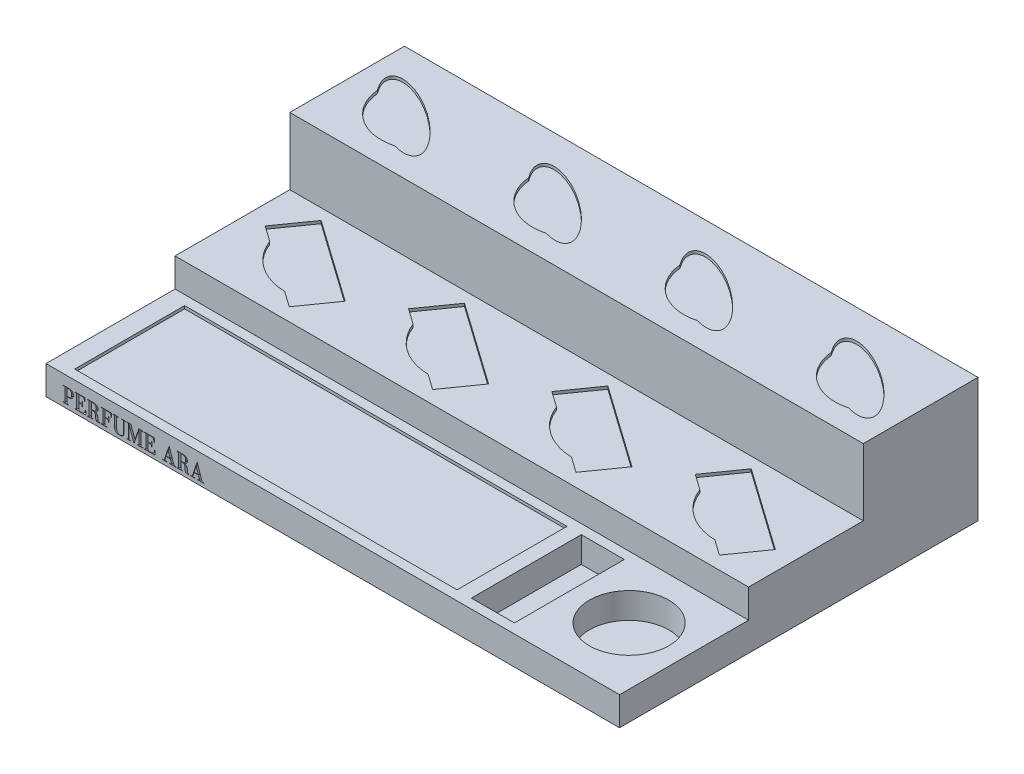
from build123d import *

# Parameters (mm, degrees)
BOSS_EXTRUDE2_DEPTH = 600
CUT_EXTRUDE3_DEPTH  = 3
CUT_EXTRUDE4_DEPTH  = 3
CUT_EXTRUDE6_DEPTH  = 3
SKETCH12_W          = 400
SKETCH12_H          = 115
CUT_EXTRUDE7_DEPTH  = 3
SKETCH13_R          = 41.5
SKETCH13_W          = 45
SKETCH13_H          = 115
CUT_EXTRUDE9_DEPTH  = 27


with BuildPart() as part:
    # Sketch2 → Boss-Extrude2 (new body)
    with BuildSketch(Plane(origin=(0, 0, 0), x_dir=(0, 0, -1), z_dir=(1, 0, 0))):
        Polygon((0, 0), (375, 0), (375, 130), (255, 130), (255, 60), (135, 60), (135, 30), (0, 30), align=None)
    extrude(amount=BOSS_EXTRUDE2_DEPTH)

    # Sketch9 → Cut-Extrude3 (cut)
    with BuildSketch(Plane(origin=(0, 130, 0), x_dir=(1, 0, 0), z_dir=(0, 1, 0))):
        with BuildLine():
            ThreePointArc((25.79283189, 320.948233658), (45.810799047, 286.377522171), (85.191812606, 279.67014765))
            add(Edge.make_bspline(
                [(85.191812606, 279.67014765), (177.980495276, 252.858739242), (72.482840424, 326.172139878), (-33.014814428, 399.485540514), (25.79283189, 320.948233658)],
                knots=[2.350232285, 2.350232285, 2.350232285, 4.722645983, 4.722645983, 7.09505968, 7.09505968, 7.09505968], degree=2, weights=[1, 0.375178634, 1, 0.375178634, 1]))
        make_face()
        with BuildLine():
            ThreePointArc((184.062227688, 320.948233658), (204.080194845, 286.377522171), (243.461208404, 279.67014765))
            add(Edge.make_bspline(
                [(243.461208404, 279.67014765), (336.249891074, 252.858739242), (230.752236222, 326.172139878), (125.25458137, 399.485540514), (184.062227688, 320.948233658)],
                knots=[5.491824939, 5.491824939, 5.491824939, 7.864238636, 7.864238636, 10.236652334, 10.236652334, 10.236652334], degree=2, weights=[1, 0.375178634, 1, 0.375178634, 1]))
        make_face()
        with BuildLine():
            ThreePointArc((342.331623486, 320.948233658), (362.349590643, 286.377522171), (401.730604202, 279.67014765))
            add(Edge.make_bspline(
                [(401.730604202, 279.67014765), (494.519286872, 252.858739242), (389.02163202, 326.172139878), (283.523977168, 399.485540514), (342.331623486, 320.948233658)],
                knots=[5.491824939, 5.491824939, 5.491824939, 7.864238636, 7.864238636, 10.236652334, 10.236652334, 10.236652334], degree=2, weights=[1, 0.375178634, 1, 0.375178634, 1]))
        make_face()
        with BuildLine():
            ThreePointArc((500.601019284, 320.948233658), (520.618986441, 286.377522171), (560, 279.67014765))
            add(Edge.make_bspline(
                [(560, 279.67014765), (652.78868267, 252.858739242), (547.291027818, 326.172139878), (441.793372966, 399.485540514), (500.601019284, 320.948233658)],
                knots=[2.350232285, 2.350232285, 2.350232285, 4.722645983, 4.722645983, 7.09505968, 7.09505968, 7.09505968], degree=2, weights=[1, 0.375178634, 1, 0.375178634, 1]))
        make_face()
    extrude(amount=-CUT_EXTRUDE3_DEPTH, mode=Mode.SUBTRACT)

    # Sketch4 → Cut-Extrude4 (cut)
    with BuildSketch(Plane(origin=(0, 60, 0), x_dir=(1, 0, 0), z_dir=(0, 1, 0))):
        with BuildLine():
            Line((20, 209.248809497), (44.223727413, 243.559318532))
            Line((44.223727413, 243.559318532), (130, 183))
            Line((130, 183), (105.776272587, 148.689490965))
            Line((105.776272587, 148.689490965), (89.437934952, 160.224599257))
            ThreePointArc((89.437934952, 160.224599257), (57.120582148, 170.799981413), (36.338337636, 197.713701205))
            Line((36.338337636, 197.713701205), (20, 209.248809497))
        make_face()
        with BuildLine():
            Line((170, 209.248809497), (194.223727413, 243.559318532))
            Line((194.223727413, 243.559318532), (280, 183))
            Line((280, 183), (255.776272587, 148.689490965))
            Line((255.776272587, 148.689490965), (239.437934952, 160.224599257))
            ThreePointArc((239.437934952, 160.224599257), (207.120582148, 170.799981413), (186.338337636, 197.713701205))
            Line((186.338337636, 197.713701205), (170, 209.248809497))
        make_face()
        with BuildLine():
            Line((320, 209.248809497), (344.223727413, 243.559318532))
            Line((344.223727413, 243.559318532), (430, 183))
            Line((430, 183), (405.776272587, 148.689490965))
            Line((405.776272587, 148.689490965), (389.437934952, 160.224599257))
            ThreePointArc((389.437934952, 160.224599257), (357.120582148, 170.799981413), (336.338337636, 197.713701205))
            Line((336.338337636, 197.713701205), (320, 209.248809497))
        make_face()
        with BuildLine():
            Line((470, 209.248809497), (494.223727413, 243.559318532))
            Line((494.223727413, 243.559318532), (580, 183))
            Line((580, 183), (555.776272587, 148.689490965))
            Line((555.776272587, 148.689490965), (539.437934952, 160.224599257))
            ThreePointArc((539.437934952, 160.224599257), (507.120582148, 170.799981413), (486.338337636, 197.713701205))
            Line((486.338337636, 197.713701205), (470, 209.248809497))
        make_face()
    extrude(amount=-CUT_EXTRUDE4_DEPTH, mode=Mode.SUBTRACT)

    # Sketch11 → Cut-Extrude6 (cut)
    with BuildSketch(Plane.XY):
        with BuildLine():
            Line((23.970966663, 19.403476125), (17.659193065, 19.403476125))
            Line((17.659193065, 19.403476125), (17.659193065, 18.981592563))
            Line((17.659193065, 18.981592563), (19.620292434, 18.981592563))
            Line((19.620292434, 18.981592563), (19.620292434, 4.426609687))
            Line((19.620292434, 4.426609687), (17.659193065, 4.426609687))
            Line((17.659193065, 4.426609687), (17.659193065, 4.004726125))
            Line((17.659193065, 4.004726125), (23.78968857, 4.004726125))
            Line((23.78968857, 4.004726125), (23.78968857, 4.426609687))
            Line((23.78968857, 4.426609687), (21.828589202, 4.426609687))
            Line((21.828589202, 4.426609687), (21.828589202, 10.965804892))
            Line((21.828589202, 10.965804892), (24.198388271, 10.965804892))
            add(Edge.make_bspline(
                [(24.198388271, 10.965804892), (24.362263502, 10.969634799), (24.68330297, 10.97713777), (25.153950282, 11.035122828), (25.603607866, 11.125284598), (26.030479945, 11.258087844), (26.431360897, 11.42627096), (26.806346754, 11.622808925), (27.148579743, 11.855675861), (27.459083097, 12.120820114), (27.741191548, 12.414504641), (27.987366433, 12.738868659), (28.204670843, 13.087716166), (28.384817195, 13.463734895), (28.531642508, 13.865024287), (28.635566174, 14.289361389), (28.700838002, 14.736559784), (28.707270095, 15.04158272), (28.710564801, 15.19782437)],
                knots=[0, 0, 0, 0, 0.000491497, 0.000962866, 0.001420519, 0.001865669, 0.002301498, 0.002723188, 0.003133652, 0.003540486, 0.003946118, 0.004352859, 0.004759881, 0.005177065, 0.005601426, 0.006039492, 0.006485569, 0.006954013, 0.006954013, 0.006954013, 0.006954013], degree=3))
            add(Edge.make_bspline(
                [(28.710564801, 15.19782437), (28.707069749, 15.349648842), (28.700175291, 15.649142948), (28.636590699, 16.087902836), (28.529940265, 16.507144992), (28.3846519, 16.90538784), (28.205382484, 17.283352022), (27.981196857, 17.630066815), (27.72670197, 17.952917853), (27.435388236, 18.246221462), (27.111569514, 18.511730124), (26.752060133, 18.742245309), (26.36273634, 18.945259659), (25.938398894, 19.108110163), (25.486598927, 19.240238323), (25.005947728, 19.336064852), (24.497443763, 19.391788422), (24.149087108, 19.399521881), (23.970966663, 19.403476125)],
                knots=[0, 0, 0, 0, 0.000455273, 0.000898087, 0.001326562, 0.001750923, 0.002168107, 0.002578637, 0.002986831, 0.003399354, 0.003816316, 0.004240511, 0.004678329, 0.005131257, 0.005601658, 0.006089037, 0.006599699, 0.007134012, 0.007134012, 0.007134012, 0.007134012], degree=3))
        make_face()
        with BuildLine():
            Line((21.828589202, 11.387688454), (21.828589202, 18.981592563))
            Line((21.828589202, 18.981592563), (23.970966663, 18.981592563))
            add(Edge.make_bspline(
                [(23.970966663, 18.981592563), (24.074343303, 18.978914527), (24.276253405, 18.973683921), (24.56975571, 18.937311183), (24.846449692, 18.877216323), (25.107220509, 18.796817819), (25.349080817, 18.687194455), (25.57214868, 18.552742157), (25.781603867, 18.399124225), (25.96990012, 18.21541073), (26.142590369, 18.005805745), (26.284695797, 17.758936841), (26.412198173, 17.482966014), (26.513484649, 17.1721739), (26.586961788, 16.827102946), (26.642004577, 16.450565856), (26.680273133, 16.041269419), (26.682428596, 15.757134009), (26.683546126, 15.609820035)],
                knots=[0, 0, 0, 0, 0.000310101, 0.000605674, 0.000885598, 0.001158706, 0.001422754, 0.001679945, 0.001939009, 0.002200078, 0.002467234, 0.002750993, 0.003051866, 0.0033781, 0.003729163, 0.004109058, 0.004519363, 0.004961133, 0.004961133, 0.004961133, 0.004961133], degree=3))
            Line((26.683546126, 15.609820035), (26.683546126, 14.782532739))
            add(Edge.make_bspline(
                [(26.683546126, 14.782532739), (26.681990815, 14.640740851), (26.678972069, 14.365533019), (26.646107097, 13.967999156), (26.590688689, 13.598853324), (26.512084035, 13.260618427), (26.414312325, 12.950786531), (26.291312402, 12.671433888), (26.14798035, 12.420444036), (25.980481649, 12.201195331), (25.79919372, 12.008827111), (25.602837587, 11.844560586), (25.399254548, 11.69937421), (25.178886029, 11.588626624), (24.950527758, 11.499159204), (24.711572531, 11.43089853), (24.458704947, 11.396043371), (24.286371692, 11.3905123), (24.198388271, 11.387688454)],
                knots=[0, 0, 0, 0, 0.000425294, 0.000825466, 0.001195584, 0.001544162, 0.001866241, 0.00216877, 0.002458215, 0.002731124, 0.002994575, 0.003249475, 0.003498162, 0.003742864, 0.003987077, 0.004233372, 0.004486475, 0.004750482, 0.004750482, 0.004750482, 0.004750482], degree=3))
            Line((24.198388271, 11.387688454), (21.828589202, 11.387688454))
        make_face(mode=Mode.SUBTRACT)
        with BuildLine():
            Line((34.366441299, 11.931522732), (36.166038367, 11.931522732))
            add(Edge.make_bspline(
                [(36.166038367, 11.931522732), (36.245205388, 11.929447122), (36.396319488, 11.925485196), (36.609857105, 11.900923765), (36.798597119, 11.855089594), (37.009717814, 11.768728881), (37.238421147, 11.618049189), (37.441950199, 11.361565427), (37.594823045, 11.052579519), (37.699964774, 10.689230195), (37.789162347, 10.279299678), (37.844359048, 9.990344353), (37.873348405, 9.838584751)],
                knots=[0, 0, 0, 0, 0.000237515, 0.00045337, 0.000643624, 0.000818062, 0.001136186, 0.001452273, 0.001788348, 0.00216468, 0.00258367, 0.003047137, 0.003047137, 0.003047137, 0.003047137], degree=3))
            add(Edge.make_bspline(
                [(37.873348405, 9.838584751), (37.883424488, 9.791504368), (37.901183756, 9.708524387), (37.948538722, 9.61214946), (37.992452901, 9.537097779), (38.037869984, 9.526743628), (38.057922464, 9.52217208)],
                knots=[0, 0, 0, 0, 0.0001431, 0.000252215, 0.000327375, 0.000386794, 0.000386794, 0.000386794, 0.000386794], degree=3))
            add(Edge.make_bspline(
                [(38.057922464, 9.52217208), (38.07896925, 9.526547508), (38.122884081, 9.535676987), (38.170111748, 9.601516617), (38.186630503, 9.698057246), (38.190709761, 9.772612501), (38.193057042, 9.815512994)],
                knots=[0, 0, 0, 0, 6.2537e-05, 0.000130485, 0.000225612, 0.000354534, 0.000354534, 0.000354534, 0.000354534], degree=3))
            Line((38.193057042, 9.815512994), (38.193057042, 14.433160414))
            add(Edge.make_bspline(
                [(38.193057042, 14.433160414), (38.19087714, 14.472883015), (38.187072434, 14.542213094), (38.168489329, 14.632137985), (38.123424782, 14.697191531), (38.079028252, 14.703653543), (38.057922464, 14.706725536)],
                knots=[0, 0, 0, 0, 0.000119066, 0.000207813, 0.000275761, 0.000337334, 0.000337334, 0.000337334, 0.000337334], degree=3))
            add(Edge.make_bspline(
                [(38.057922464, 14.706725536), (38.03788223, 14.702147504), (37.992492883, 14.691778668), (37.947744309, 14.61596046), (37.902057898, 14.517764958), (37.883662763, 14.43399029), (37.873348405, 14.3870169)],
                knots=[0, 0, 0, 0, 5.9419e-05, 0.000134578, 0.00024669, 0.000389789, 0.000389789, 0.000389789, 0.000389789], degree=3))
            add(Edge.make_bspline(
                [(37.873348405, 14.3870169), (37.844288626, 14.23528818), (37.788957841, 13.946391655), (37.700882146, 13.537091127), (37.592955174, 13.175058893), (37.444269393, 12.864532385), (37.236015188, 12.611301241), (37.010662748, 12.456633212), (36.798516295, 12.370615326), (36.609882736, 12.324645137), (36.396311957, 12.300126078), (36.245202799, 12.296157836), (36.166038367, 12.294078918)],
                knots=[0, 0, 0, 0, 0.000463467, 0.000882457, 0.001255644, 0.001594664, 0.001908214, 0.002228194, 0.002402632, 0.002592886, 0.002808741, 0.003046256, 0.003046256, 0.003046256, 0.003046256], degree=3))
            Line((36.166038367, 12.294078918), (34.366441299, 12.294078918))
            Line((34.366441299, 12.294078918), (34.366441299, 18.981592563))
            Line((34.366441299, 18.981592563), (37.830500856, 18.981592563))
            add(Edge.make_bspline(
                [(37.830500856, 18.981592563), (37.954997259, 18.977507999), (38.195085671, 18.969631011), (38.540181698, 18.899341745), (38.853975693, 18.78128646), (39.131871555, 18.611491378), (39.383431535, 18.414522838), (39.603269122, 18.186809851), (39.805340715, 17.942696144), (40.028118268, 17.581510752), (40.263108047, 17.101889599), (40.443362189, 16.499654363), (40.565125653, 15.91747208), (40.594971756, 15.53778307), (40.608999625, 15.359326671)],
                knots=[0, 0, 0, 0, 0.000373158, 0.000719627, 0.001051391, 0.001373588, 0.001692735, 0.002007375, 0.002321375, 0.002641406, 0.003278236, 0.003917254, 0.004522277, 0.005058821, 0.005058821, 0.005058821, 0.005058821], degree=3))
            add(Edge.make_bspline(
                [(40.608999625, 15.359326671), (40.609815468, 15.312813011), (40.611268644, 15.22996313), (40.644599832, 15.124449334), (40.706481722, 15.049931721), (40.762353321, 15.043054994), (40.790277718, 15.039618034)],
                knots=[0, 0, 0, 0, 0.000138783, 0.0002472, 0.000328804, 0.000410342, 0.000410342, 0.000410342, 0.000410342], degree=3))
            add(Edge.make_bspline(
                [(40.790277718, 15.039618034), (40.81457486, 15.043721233), (40.864843336, 15.05221036), (40.921853865, 15.118984272), (40.947692164, 15.217856562), (40.950294555, 15.293230754), (40.951780019, 15.336254913)],
                knots=[0, 0, 0, 0, 7.1985e-05, 0.00014893, 0.000245867, 0.00037479, 0.00037479, 0.00037479, 0.00037479], degree=3))
            Line((40.951780019, 15.336254913), (40.951780019, 18.80031447))
            add(Edge.make_bspline(
                [(40.951780019, 18.80031447), (40.949971183, 18.847734151), (40.946573801, 18.936798449), (40.919274141, 19.061180243), (40.8791871, 19.168979904), (40.812671073, 19.255676061), (40.728685377, 19.320494857), (40.630705614, 19.373847296), (40.511147339, 19.397461399), (40.426671652, 19.401382837), (40.381578018, 19.403476125)],
                knots=[0, 0, 0, 0, 0.000142071, 0.00026684, 0.000380682, 0.000484177, 0.0005897, 0.000697312, 0.000815646, 0.000951141, 0.000951141, 0.000951141, 0.000951141], degree=3))
            Line((40.381578018, 19.403476125), (30.197045163, 19.403476125))
            Line((30.197045163, 19.403476125), (30.197045163, 18.981592563))
            Line((30.197045163, 18.981592563), (32.158144531, 18.981592563))
            Line((32.158144531, 18.981592563), (32.158144531, 4.426609687))
            Line((32.158144531, 4.426609687), (30.22011692, 4.426609687))
            Line((30.22011692, 4.426609687), (30.22011692, 4.004726125))
            Line((30.22011692, 4.004726125), (40.928708262, 4.004726125))
            add(Edge.make_bspline(
                [(40.928708262, 4.004726125), (40.980597985, 4.007215093), (41.07918522, 4.011943977), (41.216177724, 4.048198373), (41.335281987, 4.108158434), (41.426886103, 4.200664277), (41.502556121, 4.312972983), (41.554362883, 4.450346848), (41.583129936, 4.612173299), (41.586239303, 4.727513837), (41.587901327, 4.789165872)],
                knots=[0, 0, 0, 0, 0.00015547, 0.000295384, 0.000422182, 0.000550386, 0.000681108, 0.000826168, 0.000987131, 0.00117197, 0.00117197, 0.00117197, 0.00117197], degree=3))
            Line((41.587901327, 4.789165872), (41.587901327, 8.207081915))
            add(Edge.make_bspline(
                [(41.587901327, 8.207081915), (41.587574812, 8.288121461), (41.587010766, 8.428115504), (41.55225768, 8.597724871), (41.503691866, 8.727514373), (41.435514249, 8.746265965), (41.406623234, 8.754212159)],
                knots=[0, 0, 0, 0, 0.000240809, 0.000415992, 0.000532521, 0.000618217, 0.000618217, 0.000618217, 0.000618217], degree=3))
            add(Edge.make_bspline(
                [(41.406623234, 8.754212159), (41.379562429, 8.746858881), (41.315686795, 8.729501849), (41.25301455, 8.619174725), (41.196247123, 8.469987615), (41.170650652, 8.346405092), (41.156129869, 8.276297187)],
                knots=[0, 0, 0, 0, 8.1404e-05, 0.000192151, 0.000354959, 0.00056841, 0.00056841, 0.00056841, 0.00056841], degree=3))
            add(Edge.make_bspline(
                [(41.156129869, 8.276297187), (41.095423397, 8.000117296), (40.979506581, 7.472761773), (40.812413243, 6.834595737), (40.659769419, 6.369171943), (40.537218057, 6.04914472), (40.386012238, 5.757730809), (40.227840213, 5.48496103), (40.044015815, 5.241900439), (39.840633565, 5.025639587), (39.609817026, 4.843284547), (39.356584428, 4.688639654), (39.07269221, 4.568308758), (38.755634117, 4.48935702), (38.407047443, 4.433585303), (38.162543976, 4.429002881), (38.034850706, 4.426609687)],
                knots=[0, 0, 0, 0, 0.000848351, 0.001619896, 0.001977398, 0.002317697, 0.002646403, 0.002961249, 0.003262501, 0.00355857, 0.0038494, 0.004142204, 0.004446452, 0.004770229, 0.0051203, 0.005502987, 0.005502987, 0.005502987, 0.005502987], degree=3))
            Line((38.034850706, 4.426609687), (34.366441299, 4.426609687))
            Line((34.366441299, 4.426609687), (34.366441299, 11.931522732))
        make_face()
        with BuildLine():
            add(Edge.make_bspline(
                [(54.554228917, 5.000107653), (54.532897788, 5.091005236), (54.48346668, 5.301644262), (54.442961059, 5.6594668), (54.421607853, 6.079904909), (54.399422433, 6.540222899), (54.39420347, 7.023919809), (54.379602152, 7.51715092), (54.364988929, 8.005318829), (54.32381311, 8.324844531), (54.303735552, 8.480647037)],
                knots=[0, 0, 0, 0, 0.000279924, 0.000648675, 0.001077961, 0.001543113, 0.002031016, 0.002528881, 0.003023814, 0.003494803, 0.003494803, 0.003494803, 0.003494803], degree=3))
            add(Edge.make_bspline(
                [(54.303735552, 8.480647037), (54.279948569, 8.627303558), (54.234132588, 8.909777896), (54.126810312, 9.30791232), (54.003535682, 9.667577579), (53.853645651, 9.98702847), (53.683471204, 10.272305434), (53.49914362, 10.532152909), (53.294739508, 10.7618477), (53.074670986, 10.967197776), (52.834634921, 11.142586154), (52.584012333, 11.308943431), (52.30997175, 11.444374565), (51.919282847, 11.60343641), (51.398486062, 11.780019133), (50.968831117, 11.899570305), (50.747388966, 11.96118642)],
                knots=[0, 0, 0, 0, 0.000445443, 0.000857966, 0.001235322, 0.001584772, 0.001914319, 0.0022308, 0.002539004, 0.002835219, 0.003131856, 0.0034299, 0.003736495, 0.004046824, 0.00469515, 0.005384668, 0.005384668, 0.005384668, 0.005384668], degree=3))
            add(Edge.make_bspline(
                [(50.747388966, 11.96118642), (50.891667453, 11.989186161), (51.173316939, 12.043845124), (51.580359965, 12.151886303), (51.95980126, 12.286016107), (52.316289813, 12.431339119), (52.64516761, 12.601497019), (52.949458531, 12.789687205), (53.23036772, 12.995844845), (53.48251291, 13.225219071), (53.705858078, 13.471897668), (53.902753737, 13.733629443), (54.067378677, 14.011494273), (54.20421183, 14.30372058), (54.309524141, 14.612119484), (54.386287946, 14.936445562), (54.42788828, 15.27694893), (54.435171537, 15.50864144), (54.438870131, 15.626299862)],
                knots=[0, 0, 0, 0, 0.000440847, 0.000860588, 0.001261898, 0.001647526, 0.002014579, 0.00237129, 0.002720008, 0.003058339, 0.003392014, 0.003716997, 0.004039193, 0.004359173, 0.004683336, 0.005015117, 0.005357295, 0.005710348, 0.005710348, 0.005710348, 0.005710348], degree=3))
            add(Edge.make_bspline(
                [(54.438870131, 15.626299862), (54.434574013, 15.77159156), (54.426158379, 16.056202449), (54.356039011, 16.471838936), (54.23668367, 16.863655324), (54.070986745, 17.23044755), (53.864922776, 17.57044017), (53.627518535, 17.885279924), (53.35549583, 18.170703453), (53.049572882, 18.424419233), (52.7159548, 18.653061795), (52.350489299, 18.851874993), (51.954699139, 19.018825358), (51.531704573, 19.155671081), (51.089474407, 19.268185582), (50.629918543, 19.346733875), (50.157284848, 19.39340431), (49.837807491, 19.400092773), (49.676200235, 19.403476125)],
                knots=[0, 0, 0, 0, 0.000435679, 0.000853448, 0.001260069, 0.001661325, 0.002057568, 0.002450452, 0.002842104, 0.003237523, 0.003640684, 0.004053667, 0.004483421, 0.004927435, 0.005386285, 0.005851203, 0.00632478, 0.006809567, 0.006809567, 0.006809567, 0.006809567], degree=3))
            Line((49.676200235, 19.403476125), (43.252363816, 19.403476125))
            Line((43.252363816, 19.403476125), (43.252363816, 18.981592563))
            Line((43.252363816, 18.981592563), (45.213463185, 18.981592563))
            Line((45.213463185, 18.981592563), (45.213463185, 4.439793548))
            Line((45.213463185, 4.439793548), (43.252363816, 4.439793548))
            Line((43.252363816, 4.439793548), (43.252363816, 4.073941397))
            Line((43.252363816, 4.073941397), (49.382859321, 4.073941397))
            Line((49.382859321, 4.073941397), (49.382859321, 4.439793548))
            Line((49.382859321, 4.439793548), (47.421759953, 4.439793548))
            Line((47.421759953, 4.439793548), (47.421759953, 11.868899391))
            Line((47.421759953, 11.868899391), (49.31364405, 11.868899391))
            add(Edge.make_bspline(
                [(49.31364405, 11.868899391), (49.439411632, 11.863119198), (49.700954704, 11.851098853), (50.025585388, 11.767880923), (50.290682835, 11.671260697), (50.488340608, 11.566592936), (50.673824179, 11.426541262), (50.856208786, 11.265971436), (51.029964177, 11.07296049), (51.186276928, 10.842652506), (51.336082257, 10.581320177), (51.46980935, 10.28275346), (51.593637892, 9.946535827), (51.697349099, 9.567228325), (51.783488098, 9.143318407), (51.82166841, 8.844614617), (51.841649454, 8.688292852)],
                knots=[0, 0, 0, 0, 0.000376909, 0.000783811, 0.000998681, 0.001222807, 0.001451562, 0.001694348, 0.001951095, 0.002228132, 0.002527793, 0.002853761, 0.003208288, 0.003601724, 0.004032223, 0.00450487, 0.00450487, 0.00450487, 0.00450487], degree=3))
            add(Edge.make_bspline(
                [(51.841649454, 8.688292852), (51.86317103, 8.489626133), (51.906490786, 8.089739361), (51.919614395, 7.486262003), (51.939177131, 6.889144402), (51.983015724, 6.312155885), (52.05842794, 5.767582699), (52.160735419, 5.341172069), (52.274285385, 5.027737505), (52.381962426, 4.813599856), (52.508499718, 4.615263346), (52.611369853, 4.497933632), (52.66234482, 4.439793548)],
                knots=[0, 0, 0, 0, 0.000599195, 0.001206092, 0.001809694, 0.002391617, 0.002941174, 0.003457579, 0.003703697, 0.003939537, 0.004175401, 0.004407081, 0.004407081, 0.004407081, 0.004407081], degree=3))
            add(Edge.make_bspline(
                [(52.66234482, 4.439793548), (52.712348924, 4.388409582), (52.810325867, 4.287728968), (52.983690018, 4.171513386), (53.16113977, 4.066964465), (53.425016656, 3.979385657), (53.776144143, 3.910486359), (54.063846245, 3.898706715), (54.211448523, 3.892663304)],
                knots=[0, 0, 0, 0, 0.000214466, 0.00042022, 0.000623824, 0.000830237, 0.001250391, 0.001693046, 0.001693046, 0.001693046, 0.001693046], degree=3))
            add(Edge.make_bspline(
                [(54.211448523, 3.892663304), (54.340229108, 3.896417173), (54.599134404, 3.903964093), (54.982500087, 3.966795236), (55.349978321, 4.055576654), (55.694488546, 4.155633493), (55.999170336, 4.272250428), (56.258961015, 4.394949642), (56.471863926, 4.507972593), (56.58026662, 4.602883862), (56.627391107, 4.644143398)],
                knots=[0, 0, 0, 0, 0.000386135, 0.0007763, 0.001162434, 0.001520119, 0.001851883, 0.002139408, 0.002383064, 0.002570442, 0.002570442, 0.002570442, 0.002570442], degree=3))
            add(Edge.make_bspline(
                [(56.627391107, 4.644143398), (56.646540222, 4.665982508), (56.68098633, 4.705267474), (56.689520512, 4.756518275), (56.693310413, 4.779277976)],
                knots=[0, 0, 0, 0, 8.5059e-05, 0.000153007, 0.000153007, 0.000153007, 0.000153007], degree=3))
            add(Edge.make_bspline(
                [(56.693310413, 4.779277976), (56.690899238, 4.799880954), (56.686213774, 4.839917245), (56.646613015, 4.845690806), (56.627391107, 4.848493248)],
                knots=[0, 0, 0, 0, 5.525e-05, 0.000107364, 0.000107364, 0.000107364, 0.000107364], degree=3))
            add(Edge.make_bspline(
                [(56.627391107, 4.848493248), (56.608447448, 4.844853743), (56.559423838, 4.8354352), (56.515754955, 4.810845545), (56.488960563, 4.795757803)],
                knots=[0, 0, 0, 0, 5.7562e-05, 0.000148961, 0.000148961, 0.000148961, 0.000148961], degree=3))
            add(Edge.make_bspline(
                [(56.488960563, 4.795757803), (56.412796009, 4.738910603), (56.262758052, 4.626926257), (56.007850004, 4.512588697), (55.740482243, 4.439317224), (55.556684252, 4.430872179), (55.463915347, 4.426609687)],
                knots=[0, 0, 0, 0, 0.000284333, 0.000560113, 0.000832723, 0.001110544, 0.001110544, 0.001110544, 0.001110544], degree=3))
            add(Edge.make_bspline(
                [(55.463915347, 4.426609687), (55.356202299, 4.432382524), (55.154023614, 4.443218208), (54.8809577, 4.554624371), (54.669173643, 4.744496083), (54.593510106, 4.912755004), (54.554228917, 5.000107653)],
                knots=[0, 0, 0, 0, 0.000321758, 0.000603943, 0.000867559, 0.001152178, 0.001152178, 0.001152178, 0.001152178], degree=3))
        make_face()
        with BuildLine():
            Line((47.421759953, 12.21497575), (47.421759953, 18.981592563))
            Line((47.421759953, 18.981592563), (49.676200235, 18.981592563))
            add(Edge.make_bspline(
                [(49.676200235, 18.981592563), (49.780635268, 18.978526951), (49.984529487, 18.972541788), (50.280658673, 18.94166836), (50.556602378, 18.881797964), (50.81086843, 18.798403353), (51.047931723, 18.698759048), (51.260428588, 18.566347735), (51.456235111, 18.416314574), (51.628669772, 18.238636648), (51.782384142, 18.039057157), (51.912586254, 17.814206199), (52.025462198, 17.568255823), (52.11850226, 17.300337209), (52.185387989, 17.007041183), (52.239190859, 16.6925862), (52.268006965, 16.353046771), (52.271573482, 16.119644568), (52.273420912, 15.998743944)],
                knots=[0, 0, 0, 0, 0.000313394, 0.000611856, 0.000891781, 0.001158612, 0.001413958, 0.00166098, 0.001907561, 0.002152285, 0.002401474, 0.002661501, 0.002929915, 0.003212389, 0.003510578, 0.003831355, 0.00416885, 0.004531541, 0.004531541, 0.004531541, 0.004531541], degree=3))
            Line((52.273420912, 15.998743944), (52.273420912, 15.178048578))
            add(Edge.make_bspline(
                [(52.273420912, 15.178048578), (52.271532506, 15.05824918), (52.267870774, 14.825950972), (52.239429444, 14.488565166), (52.185476534, 14.176294919), (52.11799756, 13.88536146), (52.02539259, 13.618473427), (51.913372049, 13.373127252), (51.782399225, 13.150733017), (51.62768557, 12.954272463), (51.456169214, 12.777189916), (51.261526777, 12.626068488), (51.045976053, 12.499487004), (50.812549668, 12.392788482), (50.555734168, 12.316219748), (50.280817023, 12.254455782), (49.984486473, 12.22414718), (49.780620699, 12.21808223), (49.676200235, 12.21497575)],
                knots=[0, 0, 0, 0, 0.000359396, 0.000696891, 0.001014417, 0.001309402, 0.001591876, 0.00186029, 0.00211748, 0.002364062, 0.002608786, 0.002855367, 0.00310069, 0.003357373, 0.003623205, 0.003903129, 0.004201591, 0.004514986, 0.004514986, 0.004514986, 0.004514986], degree=3))
            Line((49.676200235, 12.21497575), (47.421759953, 12.21497575))
        make_face(mode=Mode.SUBTRACT)
        with BuildLine():
            Line((57.711763699, 18.981592563), (59.669567102, 18.981592563))
            Line((59.669567102, 18.981592563), (59.669567102, 4.426609687))
            Line((59.669567102, 4.426609687), (57.757907213, 4.426609687))
            Line((57.757907213, 4.426609687), (57.757907213, 4.004726125))
            Line((57.757907213, 4.004726125), (63.838963238, 4.004726125))
            Line((63.838963238, 4.004726125), (63.838963238, 4.426609687))
            Line((63.838963238, 4.426609687), (61.881159835, 4.426609687))
            Line((61.881159835, 4.426609687), (61.881159835, 11.931522732))
            Line((61.881159835, 11.931522732), (63.680756903, 11.931522732))
            add(Edge.make_bspline(
                [(63.680756903, 11.931522732), (63.759948352, 11.92956696), (63.910018509, 11.925860713), (64.123229395, 11.899917366), (64.311633219, 11.856514792), (64.522304469, 11.766650793), (64.753078688, 11.619600123), (64.956316505, 11.361265909), (65.11037478, 11.053234488), (65.210378978, 10.688546308), (65.300235515, 10.279056475), (65.357809233, 9.990326166), (65.388066941, 9.838584751)],
                knots=[0, 0, 0, 0, 0.000237515, 0.000450099, 0.000643553, 0.000814943, 0.001135805, 0.001451891, 0.001787966, 0.00216333, 0.00258232, 0.003046431, 0.003046431, 0.003046431, 0.003046431], degree=3))
            add(Edge.make_bspline(
                [(65.388066941, 9.838584751), (65.398758814, 9.791844987), (65.417502374, 9.709907084), (65.458816825, 9.609934565), (65.506532627, 9.538885509), (65.550712867, 9.527129817), (65.569345034, 9.52217208)],
                knots=[0, 0, 0, 0, 0.0001431, 0.000250863, 0.00032809, 0.000384411, 0.000384411, 0.000384411, 0.000384411], degree=3))
            add(Edge.make_bspline(
                [(65.569345034, 9.52217208), (65.590188044, 9.526733291), (65.634385973, 9.536405411), (65.685565378, 9.600060693), (65.701008423, 9.698357242), (65.705303887, 9.772722074), (65.707775578, 9.815512994)],
                knots=[0, 0, 0, 0, 6.2537e-05, 0.00013261, 0.000227737, 0.000356659, 0.000356659, 0.000356659, 0.000356659], degree=3))
            Line((65.707775578, 9.815512994), (65.707775578, 14.433160414))
            add(Edge.make_bspline(
                [(65.707775578, 14.433160414), (65.705483891, 14.472784874), (65.701484081, 14.541943662), (65.683862925, 14.633531818), (65.634942661, 14.696499944), (65.590249064, 14.703466942), (65.569345034, 14.706725536)],
                knots=[0, 0, 0, 0, 0.000119066, 0.000207813, 0.000277886, 0.00033946, 0.00033946, 0.00033946, 0.00033946], degree=3))
            add(Edge.make_bspline(
                [(65.569345034, 14.706725536), (65.550722894, 14.701762974), (65.506566432, 14.68999584), (65.45798514, 14.618182065), (65.418360254, 14.516420643), (65.398986385, 14.433661416), (65.388066941, 14.3870169)],
                knots=[0, 0, 0, 0, 5.6321e-05, 0.000133548, 0.000244344, 0.000387443, 0.000387443, 0.000387443, 0.000387443], degree=3))
            add(Edge.make_bspline(
                [(65.388066941, 14.3870169), (65.357739677, 14.235305749), (65.300033611, 13.946633028), (65.211288014, 13.537783833), (65.108524635, 13.174392381), (64.958630886, 12.864835141), (64.750672428, 12.609767343), (64.523231156, 12.458725027), (64.311552521, 12.369191127), (64.123254413, 12.325651959), (63.910011117, 12.299750487), (63.759945799, 12.296037989), (63.680756903, 12.294078918)],
                knots=[0, 0, 0, 0, 0.000464111, 0.000883101, 0.001255312, 0.001594332, 0.001907882, 0.002230584, 0.002401974, 0.002595428, 0.002808011, 0.003045526, 0.003045526, 0.003045526, 0.003045526], degree=3))
            Line((63.680756903, 12.294078918), (61.881159835, 12.294078918))
            Line((61.881159835, 12.294078918), (61.881159835, 18.981592563))
            Line((61.881159835, 18.981592563), (65.341923427, 18.981592563))
            add(Edge.make_bspline(
                [(65.341923427, 18.981592563), (65.466418549, 18.977506724), (65.70650449, 18.969627277), (66.051617791, 18.899355203), (66.365350419, 18.781238847), (66.643466602, 18.611663023), (66.894829338, 18.413411711), (67.118078996, 18.187989452), (67.319903006, 17.942540918), (67.542927184, 17.581600543), (67.777795746, 17.101858963), (67.958088505, 16.499662092), (68.079842538, 15.91747044), (68.109689764, 15.537782545), (68.123718161, 15.359326671)],
                knots=[0, 0, 0, 0, 0.000373158, 0.000719627, 0.001051391, 0.001373588, 0.001692735, 0.002009697, 0.002323697, 0.002643728, 0.003280558, 0.003919576, 0.004524599, 0.005061143, 0.005061143, 0.005061143, 0.005061143], degree=3))
            add(Edge.make_bspline(
                [(68.123718161, 15.359326671), (68.124534004, 15.312813011), (68.12598718, 15.22996313), (68.159318368, 15.124449334), (68.221200258, 15.049931721), (68.277071857, 15.043054994), (68.304996254, 15.039618034)],
                knots=[0, 0, 0, 0, 0.000138783, 0.0002472, 0.000328804, 0.000410342, 0.000410342, 0.000410342, 0.000410342], degree=3))
            add(Edge.make_bspline(
                [(68.304996254, 15.039618034), (68.32950005, 15.043516762), (68.379440251, 15.051462601), (68.432742564, 15.120393385), (68.459392344, 15.217594008), (68.461818005, 15.293135346), (68.46320259, 15.336254913)],
                knots=[0, 0, 0, 0, 7.1985e-05, 0.00014671, 0.000243647, 0.000372569, 0.000372569, 0.000372569, 0.000372569], degree=3))
            Line((68.46320259, 15.336254913), (68.46320259, 18.80031447))
            add(Edge.make_bspline(
                [(68.46320259, 18.80031447), (68.461393753, 18.847734151), (68.457996371, 18.936798449), (68.430696711, 19.061180243), (68.390609671, 19.168979904), (68.324093644, 19.255676061), (68.240107947, 19.320494857), (68.142128185, 19.373847296), (68.02256991, 19.397461399), (67.938094223, 19.401382837), (67.893000589, 19.403476125)],
                knots=[0, 0, 0, 0, 0.000142071, 0.00026684, 0.000380682, 0.000484177, 0.0005897, 0.000697312, 0.000815646, 0.000951141, 0.000951141, 0.000951141, 0.000951141], degree=3))
            Line((67.893000589, 19.403476125), (57.711763699, 19.403476125))
            Line((57.711763699, 19.403476125), (57.711763699, 18.981592563))
        make_face()
        with BuildLine():
            Line((75.941747913, 19.403476125), (69.814548373, 19.403476125))
            Line((69.814548373, 19.403476125), (69.814548373, 18.981592563))
            Line((69.814548373, 18.981592563), (71.772351777, 18.981592563))
            Line((71.772351777, 18.981592563), (71.772351777, 7.841229764))
            add(Edge.make_bspline(
                [(71.772351777, 7.841229764), (71.77755125, 7.648575655), (71.787594636, 7.276441876), (71.878107456, 6.744024127), (72.021309002, 6.258076457), (72.228409131, 5.824056585), (72.481858155, 5.436092699), (72.769802237, 5.089220086), (73.089242062, 4.77844271), (73.442574641, 4.50807719), (73.826018827, 4.279143326), (74.229594022, 4.083576141), (74.654251742, 3.924198968), (75.097428515, 3.80455252), (75.549689405, 3.717611828), (76.003094694, 3.655499971), (76.452938314, 3.61357371), (76.752464978, 3.60845201), (76.900873823, 3.605914321)],
                knots=[0, 0, 0, 0, 0.000577556, 0.001115617, 0.001615051, 0.002092738, 0.002552582, 0.003002019, 0.003442558, 0.003886878, 0.004333429, 0.00478009, 0.005230662, 0.005692027, 0.006155494, 0.006611363, 0.007064639, 0.00750979, 0.00750979, 0.00750979, 0.00750979], degree=3))
            add(Edge.make_bspline(
                [(76.900873823, 3.605914321), (77.075677388, 3.608953601), (77.417224019, 3.614892015), (77.914160996, 3.664620644), (78.382582614, 3.746761565), (78.820781414, 3.8609958), (79.230293526, 4.008788967), (79.606488649, 4.195172735), (79.955740883, 4.409411259), (80.273548568, 4.657559609), (80.560186619, 4.938837799), (80.806873267, 5.256599436), (81.018095543, 5.606484914), (81.183982715, 5.991197904), (81.317137294, 6.407238323), (81.411438139, 6.855515486), (81.46777079, 7.337709903), (81.475154242, 7.669682216), (81.47896966, 7.841229764)],
                knots=[0, 0, 0, 0, 0.000524318, 0.001024458, 0.001496437, 0.001949725, 0.002381409, 0.002800035, 0.003207057, 0.003608584, 0.004007123, 0.004408649, 0.00481224, 0.005229893, 0.005662468, 0.006120797, 0.006601986, 0.007116536, 0.007116536, 0.007116536, 0.007116536], degree=3))
            Line((81.47896966, 7.841229764), (81.47896966, 18.981592563))
            Line((81.47896966, 18.981592563), (83.436773063, 18.981592563))
            Line((83.436773063, 18.981592563), (83.436773063, 19.403476125))
            Line((83.436773063, 19.403476125), (79.155314105, 19.403476125))
            Line((79.155314105, 19.403476125), (79.155314105, 18.981592563))
            Line((79.155314105, 18.981592563), (81.113117509, 18.981592563))
            Line((81.113117509, 18.981592563), (81.113117509, 7.841229764))
            add(Edge.make_bspline(
                [(81.113117509, 7.841229764), (81.110364555, 7.693841101), (81.104983662, 7.405756883), (81.050930764, 6.985321043), (80.963086985, 6.58750482), (80.836688036, 6.215206401), (80.682919095, 5.86763028), (80.497424138, 5.549846062), (80.284616939, 5.261035207), (80.048497266, 4.999786679), (79.784322365, 4.771498169), (79.502077178, 4.569103576), (79.194403316, 4.400866521), (78.870558195, 4.259150298), (78.527789767, 4.150540982), (78.172794287, 4.071395863), (77.803019721, 4.02447326), (77.552510119, 4.017940818), (77.42493231, 4.014614021)],
                knots=[0, 0, 0, 0, 0.000441967, 0.000863863, 0.001269267, 0.001662206, 0.002041371, 0.002407683, 0.002763663, 0.003115961, 0.003461676, 0.003809194, 0.004155897, 0.004511648, 0.004868131, 0.005232778, 0.005601529, 0.005984216, 0.005984216, 0.005984216, 0.005984216], degree=3))
            add(Edge.make_bspline(
                [(77.42493231, 4.014614021), (77.295137004, 4.017802621), (77.04238914, 4.024011719), (76.674083738, 4.071593438), (76.325683881, 4.145745554), (75.999002086, 4.255201695), (75.691972454, 4.393871218), (75.40786343, 4.567084435), (75.142621422, 4.768028556), (74.901526844, 5.001044562), (74.681257284, 5.259892819), (74.500182077, 5.554524317), (74.333405678, 5.867604978), (74.209505929, 6.212938058), (74.103068764, 6.580874636), (74.039594999, 6.978311257), (73.988654027, 7.400464534), (73.985542918, 7.691634254), (73.98394451, 7.841229764)],
                knots=[0, 0, 0, 0, 0.000389273, 0.000758024, 0.001112305, 0.001456256, 0.001789589, 0.002120829, 0.002452414, 0.002785763, 0.003125055, 0.003468849, 0.003821162, 0.004187252, 0.004567104, 0.00496863, 0.00539303, 0.005841475, 0.005841475, 0.005841475, 0.005841475], degree=3))
            Line((73.98394451, 7.841229764), (73.98394451, 18.981592563))
            Line((73.98394451, 18.981592563), (75.941747913, 18.981592563))
            Line((75.941747913, 18.981592563), (75.941747913, 19.403476125))
        make_face()
        Polygon((84.643096372, 4.426609687), (84.643096372, 4.004726125), (88.654286173, 4.004726125), (88.654286173, 4.426609687), (86.831617348, 4.426609687), (86.831617348, 18.619036378), (91.910699914, 4.004726125), (92.207336794, 4.004726125), (97.28641936, 18.708027441), (97.28641936, 4.426609687), (95.463750535, 4.426609687), (95.463750535, 4.004726125), (101.320680918, 4.004726125), (101.320680918, 4.426609687), (99.498012093, 4.426609687), (99.498012093, 18.981592563), (101.320680918, 18.981592563), (101.320680918, 19.403476125), (97.105141267, 19.403476125), (93.051103917, 7.692911324), (88.858636023, 19.403476125), (84.643096372, 19.403476125), (84.643096372, 18.981592563), (86.465765197, 18.981592563), (86.465765197, 4.426609687), align=None)
        with BuildLine():
            Line((106.930413902, 11.931522732), (108.73001097, 11.931522732))
            add(Edge.make_bspline(
                [(108.73001097, 11.931522732), (108.809177991, 11.929447122), (108.960292091, 11.925485196), (109.173829708, 11.900923765), (109.362569722, 11.855089594), (109.573690416, 11.768728881), (109.80239375, 11.618049189), (110.005922801, 11.361565427), (110.158795648, 11.052579519), (110.263937377, 10.689230195), (110.35313495, 10.279299678), (110.40833165, 9.990344353), (110.437321008, 9.838584751)],
                knots=[0, 0, 0, 0, 0.000237515, 0.00045337, 0.000643624, 0.000818062, 0.001136186, 0.001452273, 0.001788348, 0.00216468, 0.00258367, 0.003047137, 0.003047137, 0.003047137, 0.003047137], degree=3))
            add(Edge.make_bspline(
                [(110.437321008, 9.838584751), (110.447397091, 9.791504368), (110.465156359, 9.708524387), (110.512511325, 9.61214946), (110.556425504, 9.537097779), (110.601842587, 9.526743628), (110.621895066, 9.52217208)],
                knots=[0, 0, 0, 0, 0.0001431, 0.000252215, 0.000327375, 0.000386794, 0.000386794, 0.000386794, 0.000386794], degree=3))
            add(Edge.make_bspline(
                [(110.621895066, 9.52217208), (110.642941853, 9.526547508), (110.686856684, 9.535676987), (110.734084351, 9.601516617), (110.750603106, 9.698057246), (110.754682363, 9.772612501), (110.757029645, 9.815512994)],
                knots=[0, 0, 0, 0, 6.2537e-05, 0.000130485, 0.000225612, 0.000354534, 0.000354534, 0.000354534, 0.000354534], degree=3))
            Line((110.757029645, 9.815512994), (110.757029645, 14.433160414))
            add(Edge.make_bspline(
                [(110.757029645, 14.433160414), (110.754849742, 14.472883015), (110.751045037, 14.542213094), (110.732461932, 14.632137985), (110.687397385, 14.697191531), (110.643000854, 14.703653543), (110.621895066, 14.706725536)],
                knots=[0, 0, 0, 0, 0.000119066, 0.000207813, 0.000275761, 0.000337334, 0.000337334, 0.000337334, 0.000337334], degree=3))
            add(Edge.make_bspline(
                [(110.621895066, 14.706725536), (110.601854833, 14.702147504), (110.556465486, 14.691778668), (110.511716912, 14.61596046), (110.466030501, 14.517764958), (110.447635365, 14.43399029), (110.437321008, 14.3870169)],
                knots=[0, 0, 0, 0, 5.9419e-05, 0.000134578, 0.00024669, 0.000389789, 0.000389789, 0.000389789, 0.000389789], degree=3))
            add(Edge.make_bspline(
                [(110.437321008, 14.3870169), (110.408261229, 14.23528818), (110.352930444, 13.946391655), (110.264854749, 13.537091127), (110.156927777, 13.175058893), (110.008241995, 12.864532385), (109.79998779, 12.611301241), (109.57463535, 12.456633212), (109.362488898, 12.370615326), (109.173855338, 12.324645137), (108.960284559, 12.300126078), (108.809175402, 12.296157836), (108.73001097, 12.294078918)],
                knots=[0, 0, 0, 0, 0.000463467, 0.000882457, 0.001255644, 0.001594664, 0.001908214, 0.002228194, 0.002402632, 0.002592886, 0.002808741, 0.003046256, 0.003046256, 0.003046256, 0.003046256], degree=3))
            Line((108.73001097, 12.294078918), (106.930413902, 12.294078918))
            Line((106.930413902, 12.294078918), (106.930413902, 18.981592563))
            Line((106.930413902, 18.981592563), (110.394473459, 18.981592563))
            add(Edge.make_bspline(
                [(110.394473459, 18.981592563), (110.518969862, 18.977507999), (110.759058274, 18.969631011), (111.1041543, 18.899341745), (111.417948295, 18.78128646), (111.695844157, 18.611491378), (111.947404138, 18.414522838), (112.167241725, 18.186809851), (112.369313318, 17.942696144), (112.592090871, 17.581510752), (112.82708065, 17.101889599), (113.007334792, 16.499654363), (113.129098256, 15.91747208), (113.158944358, 15.53778307), (113.172972228, 15.359326671)],
                knots=[0, 0, 0, 0, 0.000373158, 0.000719627, 0.001051391, 0.001373588, 0.001692735, 0.002007375, 0.002321375, 0.002641406, 0.003278236, 0.003917254, 0.004522277, 0.005058821, 0.005058821, 0.005058821, 0.005058821], degree=3))
            add(Edge.make_bspline(
                [(113.172972228, 15.359326671), (113.173788071, 15.312813011), (113.175241246, 15.22996313), (113.208572434, 15.124449334), (113.270454325, 15.049931721), (113.326325924, 15.043054994), (113.354250321, 15.039618034)],
                knots=[0, 0, 0, 0, 0.000138783, 0.0002472, 0.000328804, 0.000410342, 0.000410342, 0.000410342, 0.000410342], degree=3))
            add(Edge.make_bspline(
                [(113.354250321, 15.039618034), (113.378547463, 15.043721233), (113.428815939, 15.05221036), (113.485826468, 15.118984272), (113.511664767, 15.217856562), (113.514267158, 15.293230754), (113.515752622, 15.336254913)],
                knots=[0, 0, 0, 0, 7.1985e-05, 0.00014893, 0.000245867, 0.00037479, 0.00037479, 0.00037479, 0.00037479], degree=3))
            Line((113.515752622, 15.336254913), (113.515752622, 18.80031447))
            add(Edge.make_bspline(
                [(113.515752622, 18.80031447), (113.513943785, 18.847734151), (113.510546403, 18.936798449), (113.483246743, 19.061180243), (113.443159703, 19.168979904), (113.376643676, 19.255676061), (113.29265798, 19.320494857), (113.194678217, 19.373847296), (113.075119942, 19.397461399), (112.990644255, 19.401382837), (112.945550621, 19.403476125)],
                knots=[0, 0, 0, 0, 0.000142071, 0.00026684, 0.000380682, 0.000484177, 0.0005897, 0.000697312, 0.000815646, 0.000951141, 0.000951141, 0.000951141, 0.000951141], degree=3))
            Line((112.945550621, 19.403476125), (102.761017765, 19.403476125))
            Line((102.761017765, 19.403476125), (102.761017765, 18.981592563))
            Line((102.761017765, 18.981592563), (104.722117134, 18.981592563))
            Line((104.722117134, 18.981592563), (104.722117134, 4.426609687))
            Line((104.722117134, 4.426609687), (102.784089523, 4.426609687))
            Line((102.784089523, 4.426609687), (102.784089523, 4.004726125))
            Line((102.784089523, 4.004726125), (113.492680865, 4.004726125))
            add(Edge.make_bspline(
                [(113.492680865, 4.004726125), (113.544570588, 4.007215093), (113.643157823, 4.011943977), (113.780150327, 4.048198373), (113.89925459, 4.108158434), (113.990858705, 4.200664277), (114.066528724, 4.312972983), (114.118335486, 4.450346848), (114.147102539, 4.612173299), (114.150211906, 4.727513837), (114.15187393, 4.789165872)],
                knots=[0, 0, 0, 0, 0.00015547, 0.000295384, 0.000422182, 0.000550386, 0.000681108, 0.000826168, 0.000987131, 0.00117197, 0.00117197, 0.00117197, 0.00117197], degree=3))
            Line((114.15187393, 4.789165872), (114.15187393, 8.207081915))
            add(Edge.make_bspline(
                [(114.15187393, 8.207081915), (114.151547415, 8.288121461), (114.150983368, 8.428115504), (114.116230282, 8.597724871), (114.067664469, 8.727514373), (113.999486852, 8.746265965), (113.970595837, 8.754212159)],
                knots=[0, 0, 0, 0, 0.000240809, 0.000415992, 0.000532521, 0.000618217, 0.000618217, 0.000618217, 0.000618217], degree=3))
            add(Edge.make_bspline(
                [(113.970595837, 8.754212159), (113.943535031, 8.746858881), (113.879659398, 8.729501849), (113.816987153, 8.619174725), (113.760219726, 8.469987615), (113.734623255, 8.346405092), (113.720102472, 8.276297187)],
                knots=[0, 0, 0, 0, 8.1404e-05, 0.000192151, 0.000354959, 0.00056841, 0.00056841, 0.00056841, 0.00056841], degree=3))
            add(Edge.make_bspline(
                [(113.720102472, 8.276297187), (113.659396, 8.000117296), (113.543479184, 7.472761773), (113.376385846, 6.834595737), (113.223742022, 6.369171943), (113.10119066, 6.04914472), (112.94998484, 5.757730809), (112.791812816, 5.48496103), (112.607988418, 5.241900439), (112.404606168, 5.025639587), (112.173789629, 4.843284547), (111.920557031, 4.688639654), (111.636664812, 4.568308758), (111.31960672, 4.48935702), (110.971020046, 4.433585303), (110.726516579, 4.429002881), (110.598823309, 4.426609687)],
                knots=[0, 0, 0, 0, 0.000848351, 0.001619896, 0.001977398, 0.002317697, 0.002646403, 0.002961249, 0.003262501, 0.00355857, 0.0038494, 0.004142204, 0.004446452, 0.004770229, 0.0051203, 0.005502987, 0.005502987, 0.005502987, 0.005502987], degree=3))
            Line((110.598823309, 4.426609687), (106.930413902, 4.426609687))
            Line((106.930413902, 4.426609687), (106.930413902, 11.931522732))
        make_face()
        Polygon((121.706226455, 4.426609687), (121.706226455, 4.004726125), (126.76553323, 4.004726125), (126.76553323, 4.426609687), (124.076025524, 4.426609687), (125.509770441, 8.645445303), (130.091162243, 8.645445303), (131.571050674, 4.426609687), (129.224323363, 4.426609687), (129.224323363, 4.004726125), (135.898653146, 4.004726125), (135.898653146, 4.426609687), (133.917777986, 4.426609687), (128.927686483, 19.403476125), (128.654121361, 19.403476125), (123.664029859, 4.426609687), align=None)
        Polygon((127.790578446, 15.583452313), (129.975803457, 9.067328865), (125.648200985, 9.067328865), align=None, mode=Mode.SUBTRACT)
        with BuildLine():
            add(Edge.make_bspline(
                [(148.212379602, 5.000107653), (148.191048473, 5.091005236), (148.141617365, 5.301644262), (148.101111744, 5.6594668), (148.079758538, 6.079904909), (148.057573118, 6.540222899), (148.052354155, 7.023919809), (148.037752837, 7.51715092), (148.023139614, 8.005318829), (147.981963795, 8.324844531), (147.961886237, 8.480647037)],
                knots=[0, 0, 0, 0, 0.000279924, 0.000648675, 0.001077961, 0.001543113, 0.002031016, 0.002528881, 0.003023814, 0.003494803, 0.003494803, 0.003494803, 0.003494803], degree=3))
            add(Edge.make_bspline(
                [(147.961886237, 8.480647037), (147.938099254, 8.627303558), (147.892283273, 8.909777896), (147.784960997, 9.30791232), (147.661686367, 9.667577579), (147.511796336, 9.98702847), (147.341621888, 10.272305434), (147.157294305, 10.532152909), (146.952890193, 10.7618477), (146.732821671, 10.967197776), (146.492785606, 11.142586154), (146.242163018, 11.308943431), (145.968122434, 11.444374565), (145.577433532, 11.60343641), (145.056636746, 11.780019133), (144.626981801, 11.899570305), (144.405539651, 11.96118642)],
                knots=[0, 0, 0, 0, 0.000445443, 0.000857966, 0.001235322, 0.001584772, 0.001914319, 0.0022308, 0.002539004, 0.002835219, 0.003131856, 0.0034299, 0.003736495, 0.004046824, 0.00469515, 0.005384668, 0.005384668, 0.005384668, 0.005384668], degree=3))
            add(Edge.make_bspline(
                [(144.405539651, 11.96118642), (144.549818138, 11.989186161), (144.831467624, 12.043845124), (145.23851065, 12.151886303), (145.617951945, 12.286016107), (145.974440498, 12.431339119), (146.303318295, 12.601497019), (146.607609216, 12.789687205), (146.888518405, 12.995844845), (147.140663595, 13.225219071), (147.364008763, 13.471897668), (147.560904422, 13.733629443), (147.725529362, 14.011494273), (147.862362515, 14.30372058), (147.967674826, 14.612119484), (148.044438631, 14.936445562), (148.086038965, 15.27694893), (148.093322222, 15.50864144), (148.097020815, 15.626299862)],
                knots=[0, 0, 0, 0, 0.000440847, 0.000860588, 0.001261898, 0.001647526, 0.002014579, 0.00237129, 0.002720008, 0.003058339, 0.003392014, 0.003716997, 0.004039193, 0.004359173, 0.004683336, 0.005015117, 0.005357295, 0.005710348, 0.005710348, 0.005710348, 0.005710348], degree=3))
            add(Edge.make_bspline(
                [(148.097020815, 15.626299862), (148.092724698, 15.77159156), (148.084309064, 16.056202449), (148.014189696, 16.471838936), (147.894834355, 16.863655324), (147.72913743, 17.23044755), (147.523073461, 17.57044017), (147.285669219, 17.885279924), (147.013646515, 18.170703453), (146.707723567, 18.424419233), (146.374105485, 18.653061795), (146.008639983, 18.851874993), (145.612849824, 19.018825358), (145.189855258, 19.155671081), (144.747625092, 19.268185582), (144.288069227, 19.346733875), (143.815435533, 19.39340431), (143.495958176, 19.400092773), (143.33435092, 19.403476125)],
                knots=[0, 0, 0, 0, 0.000435679, 0.000853448, 0.001260069, 0.001661325, 0.002057568, 0.002450452, 0.002842104, 0.003237523, 0.003640684, 0.004053667, 0.004483421, 0.004927435, 0.005386285, 0.005851203, 0.00632478, 0.006809567, 0.006809567, 0.006809567, 0.006809567], degree=3))
            Line((143.33435092, 19.403476125), (136.910514501, 19.403476125))
            Line((136.910514501, 19.403476125), (136.910514501, 18.981592563))
            Line((136.910514501, 18.981592563), (138.87161387, 18.981592563))
            Line((138.87161387, 18.981592563), (138.87161387, 4.439793548))
            Line((138.87161387, 4.439793548), (136.910514501, 4.439793548))
            Line((136.910514501, 4.439793548), (136.910514501, 4.073941397))
            Line((136.910514501, 4.073941397), (143.041010006, 4.073941397))
            Line((143.041010006, 4.073941397), (143.041010006, 4.439793548))
            Line((143.041010006, 4.439793548), (141.079910638, 4.439793548))
            Line((141.079910638, 4.439793548), (141.079910638, 11.868899391))
            Line((141.079910638, 11.868899391), (142.971794735, 11.868899391))
            add(Edge.make_bspline(
                [(142.971794735, 11.868899391), (143.097562316, 11.863119198), (143.359105389, 11.851098853), (143.683736073, 11.767880923), (143.94883352, 11.671260697), (144.146491293, 11.566592936), (144.331974864, 11.426541262), (144.51435947, 11.265971436), (144.688114862, 11.07296049), (144.844427613, 10.842652506), (144.994232942, 10.581320177), (145.127960035, 10.28275346), (145.251788577, 9.946535827), (145.355499784, 9.567228325), (145.441638783, 9.143318407), (145.479819095, 8.844614617), (145.499800139, 8.688292852)],
                knots=[0, 0, 0, 0, 0.000376909, 0.000783811, 0.000998681, 0.001222807, 0.001451562, 0.001694348, 0.001951095, 0.002228132, 0.002527793, 0.002853761, 0.003208288, 0.003601724, 0.004032223, 0.00450487, 0.00450487, 0.00450487, 0.00450487], degree=3))
            add(Edge.make_bspline(
                [(145.499800139, 8.688292852), (145.521321715, 8.489626133), (145.564641471, 8.089739361), (145.57776508, 7.486262003), (145.597327816, 6.889144402), (145.641166409, 6.312155885), (145.716578625, 5.767582699), (145.818886104, 5.341172069), (145.932436069, 5.027737505), (146.04011311, 4.813599856), (146.166650403, 4.615263346), (146.269520538, 4.497933632), (146.320495505, 4.439793548)],
                knots=[0, 0, 0, 0, 0.000599195, 0.001206092, 0.001809694, 0.002391617, 0.002941174, 0.003457579, 0.003703697, 0.003939537, 0.004175401, 0.004407081, 0.004407081, 0.004407081, 0.004407081], degree=3))
            add(Edge.make_bspline(
                [(146.320495505, 4.439793548), (146.370499609, 4.388409582), (146.468476551, 4.287728968), (146.641840703, 4.171513386), (146.819290454, 4.066964465), (147.083167341, 3.979385657), (147.434294828, 3.910486359), (147.72199693, 3.898706715), (147.869599208, 3.892663304)],
                knots=[0, 0, 0, 0, 0.000214466, 0.00042022, 0.000623824, 0.000830237, 0.001250391, 0.001693046, 0.001693046, 0.001693046, 0.001693046], degree=3))
            add(Edge.make_bspline(
                [(147.869599208, 3.892663304), (147.998379793, 3.896417173), (148.257285088, 3.903964093), (148.640650772, 3.966795236), (149.008129006, 4.055576654), (149.352639231, 4.155633493), (149.657321021, 4.272250428), (149.9171117, 4.394949642), (150.130014611, 4.507972593), (150.238417304, 4.602883862), (150.285541792, 4.644143398)],
                knots=[0, 0, 0, 0, 0.000386135, 0.0007763, 0.001162434, 0.001520119, 0.001851883, 0.002139408, 0.002383064, 0.002570442, 0.002570442, 0.002570442, 0.002570442], degree=3))
            add(Edge.make_bspline(
                [(150.285541792, 4.644143398), (150.304690907, 4.665982508), (150.339137015, 4.705267474), (150.347671197, 4.756518275), (150.351461098, 4.779277976)],
                knots=[0, 0, 0, 0, 8.5059e-05, 0.000153007, 0.000153007, 0.000153007, 0.000153007], degree=3))
            add(Edge.make_bspline(
                [(150.351461098, 4.779277976), (150.349049923, 4.799880954), (150.344364459, 4.839917245), (150.3047637, 4.845690806), (150.285541792, 4.848493248)],
                knots=[0, 0, 0, 0, 5.525e-05, 0.000107364, 0.000107364, 0.000107364, 0.000107364], degree=3))
            add(Edge.make_bspline(
                [(150.285541792, 4.848493248), (150.266598133, 4.844853743), (150.217574523, 4.8354352), (150.17390564, 4.810845545), (150.147111248, 4.795757803)],
                knots=[0, 0, 0, 0, 5.7562e-05, 0.000148961, 0.000148961, 0.000148961, 0.000148961], degree=3))
            add(Edge.make_bspline(
                [(150.147111248, 4.795757803), (150.070946694, 4.738910603), (149.920908737, 4.626926257), (149.666000689, 4.512588697), (149.398632928, 4.439317224), (149.214834937, 4.430872179), (149.122066032, 4.426609687)],
                knots=[0, 0, 0, 0, 0.000284333, 0.000560113, 0.000832723, 0.001110544, 0.001110544, 0.001110544, 0.001110544], degree=3))
            add(Edge.make_bspline(
                [(149.122066032, 4.426609687), (149.014352984, 4.432382524), (148.812174299, 4.443218208), (148.539108385, 4.554624371), (148.327324328, 4.744496083), (148.251660791, 4.912755004), (148.212379602, 5.000107653)],
                knots=[0, 0, 0, 0, 0.000321758, 0.000603943, 0.000867559, 0.001152178, 0.001152178, 0.001152178, 0.001152178], degree=3))
        make_face()
        with BuildLine():
            Line((141.079910638, 12.21497575), (141.079910638, 18.981592563))
            Line((141.079910638, 18.981592563), (143.33435092, 18.981592563))
            add(Edge.make_bspline(
                [(143.33435092, 18.981592563), (143.438785953, 18.978526951), (143.642680172, 18.972541788), (143.938809358, 18.94166836), (144.214753063, 18.881797964), (144.469019115, 18.798403353), (144.706082408, 18.698759048), (144.918579273, 18.566347735), (145.114385796, 18.416314574), (145.286820457, 18.238636648), (145.440534827, 18.039057157), (145.570736939, 17.814206199), (145.683612882, 17.568255823), (145.776652945, 17.300337209), (145.843538674, 17.007041183), (145.897341544, 16.6925862), (145.92615765, 16.353046771), (145.929724167, 16.119644568), (145.931571597, 15.998743944)],
                knots=[0, 0, 0, 0, 0.000313394, 0.000611856, 0.000891781, 0.001158612, 0.001413958, 0.00166098, 0.001907561, 0.002152285, 0.002401474, 0.002661501, 0.002929915, 0.003212389, 0.003510578, 0.003831355, 0.00416885, 0.004531541, 0.004531541, 0.004531541, 0.004531541], degree=3))
            Line((145.931571597, 15.998743944), (145.931571597, 15.178048578))
            add(Edge.make_bspline(
                [(145.931571597, 15.178048578), (145.929683191, 15.05824918), (145.926021458, 14.825950972), (145.897580129, 14.488565166), (145.843627219, 14.176294919), (145.776148245, 13.88536146), (145.683543275, 13.618473427), (145.571522734, 13.373127252), (145.44054991, 13.150733017), (145.285836255, 12.954272463), (145.114319899, 12.777189916), (144.919677462, 12.626068488), (144.704126738, 12.499487004), (144.470700353, 12.392788482), (144.213884853, 12.316219748), (143.938967707, 12.254455782), (143.642637158, 12.22414718), (143.438771384, 12.21808223), (143.33435092, 12.21497575)],
                knots=[0, 0, 0, 0, 0.000359396, 0.000696891, 0.001014417, 0.001309402, 0.001591876, 0.00186029, 0.00211748, 0.002364062, 0.002608786, 0.002855367, 0.00310069, 0.003357373, 0.003623205, 0.003903129, 0.004201591, 0.004514986, 0.004514986, 0.004514986, 0.004514986], degree=3))
            Line((143.33435092, 12.21497575), (141.079910638, 12.21497575))
        make_face(mode=Mode.SUBTRACT)
        Polygon((151.02713399, 4.426609687), (151.02713399, 4.004726125), (156.086440764, 4.004726125), (156.086440764, 4.426609687), (153.396933059, 4.426609687), (154.830677975, 8.645445303), (159.412069777, 8.645445303), (160.891958208, 4.426609687), (158.545230897, 4.426609687), (158.545230897, 4.004726125), (165.219560681, 4.004726125), (165.219560681, 4.426609687), (163.23868552, 4.426609687), (158.248594018, 19.403476125), (157.975028896, 19.403476125), (152.984937393, 4.426609687), align=None)
        Polygon((157.11148598, 15.583452313), (159.296710991, 9.067328865), (154.969108519, 9.067328865), align=None, mode=Mode.SUBTRACT)
    extrude(amount=-CUT_EXTRUDE6_DEPTH, mode=Mode.SUBTRACT)

    # Sketch12 → Cut-Extrude7 (cut)
    with BuildSketch(Plane(origin=(0, 30, 0), x_dir=(1, 0, 0), z_dir=(0, 1, 0))):
        with Locations((220, 67.5)):
            Rectangle(SKETCH12_W, SKETCH12_H)
    extrude(amount=-CUT_EXTRUDE7_DEPTH, mode=Mode.SUBTRACT)

    # Sketch13 → Cut-Extrude9 (cut)
    with BuildSketch(Plane(origin=(0, 30, 0), x_dir=(1, 0, 0), z_dir=(0, 1, 0))):
        with Locations((540, 70)):
            Circle(SKETCH13_R)
        with Locations((457.5, 67.5)):
            Rectangle(SKETCH13_W, SKETCH13_H)
    extrude(amount=-CUT_EXTRUDE9_DEPTH, mode=Mode.SUBTRACT)


solid = part.part
